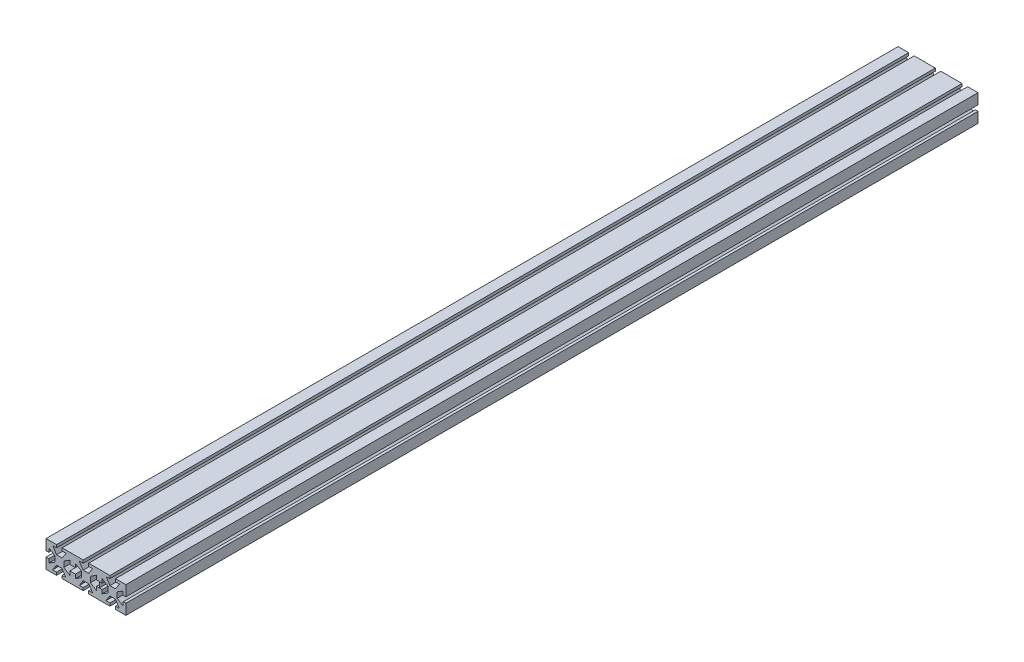
from build123d import *

# Parameters (mm, degrees)
SKETCH1_W            = 114.3
SKETCH1_H            = 1219.2
BASE_EXTRUDE_DEPTH   = 38.1
CUT_EXTRUDE1_DEPTH   = 1220.2
MIRROR2_COPY_1_DEPTH = 1220.2
MIRROR2_COPY_2_DEPTH = 1220.2


with BuildPart() as part:
    # Sketch1 → Base Extrude (new body)
    with BuildSketch(Plane(origin=(0, 0, 0), x_dir=(1, 0, 0), z_dir=(0, 1, 0))):
        Rectangle(SKETCH1_W, SKETCH1_H)
    extrude(amount=BASE_EXTRUDE_DEPTH)

    # Sketch3 → Cut-Extrude1 (cut, through all)
    with BuildSketch(Plane.XY.offset(609.6)):
        Polygon((-42.06875, 38.1), (-34.13125, 38.1), (-34.13125, 34.13125), (-28.347265172, 34.13125), (-34.13125, 25.49525), (-42.06875, 25.49525), (-47.397265172, 34.13125), (-42.06875, 34.13125), align=None)
        Polygon((-23.01875, 28.347265172), (-23.01875, 23.01875), (-19.05, 23.01875), (-19.05, 15.08125), (-23.01875, 15.08125), (-23.01875, 9.297265172), (-31.65475, 15.08125), (-31.65475, 23.01875), align=None)
        Polygon((-28.802734828, 3.96875), (-34.13125, 3.96875), (-34.13125, 0), (-42.06875, 0), (-42.06875, 3.96875), (-47.852734828, 3.96875), (-42.06875, 12.60475), (-34.13125, 12.60475), align=None)
        Polygon((-53.18125, 9.752734828), (-53.18125, 15.08125), (-57.15, 15.08125), (-57.15, 23.01875), (-53.18125, 23.01875), (-53.18125, 28.802734828), (-44.54525, 23.01875), (-44.54525, 15.08125), align=None)
    cut_extrude1 = extrude(amount=-CUT_EXTRUDE1_DEPTH, mode=Mode.SUBTRACT)

    # Mirror1: Cut-Extrude1 across plane
    add(cut_extrude1.mirror(Plane.ZY.offset(19.05)), mode=Mode.SUBTRACT)

    # Mirror2 copy 1 sketch → Mirror2 copy 1 (cut, through all)
    with BuildSketch(Plane(origin=(76.3905, 0, 609.6), x_dir=(1, 0, 0), z_dir=(0, 0, 1))):
        Polygon((-42.06875, 38.1), (-34.13125, 38.1), (-34.13125, 34.13125), (-28.347265172, 34.13125), (-34.13125, 25.49525), (-42.06875, 25.49525), (-47.397265172, 34.13125), (-42.06875, 34.13125), align=None)
        Polygon((-23.01875, 28.347265172), (-23.01875, 23.01875), (-19.05, 23.01875), (-19.05, 15.08125), (-23.01875, 15.08125), (-23.01875, 9.297265172), (-31.65475, 15.08125), (-31.65475, 23.01875), align=None)
        Polygon((-28.802734828, 3.96875), (-34.13125, 3.96875), (-34.13125, 0), (-42.06875, 0), (-42.06875, 3.96875), (-47.852734828, 3.96875), (-42.06875, 12.60475), (-34.13125, 12.60475), align=None)
        Polygon((-53.18125, 9.752734828), (-53.18125, 15.08125), (-57.15, 15.08125), (-57.15, 23.01875), (-53.18125, 23.01875), (-53.18125, 28.802734828), (-44.54525, 23.01875), (-44.54525, 15.08125), align=None)
    extrude(amount=-MIRROR2_COPY_1_DEPTH, mode=Mode.SUBTRACT)

    # Mirror2 copy 2 sketch → Mirror2 copy 2 (cut, through all)
    with BuildSketch(Plane(origin=(38.2905, 0, 609.6), x_dir=(-1, 0, 0), z_dir=(0, 0, 1))):
        Polygon((-42.06875, -38.1), (-34.13125, -38.1), (-34.13125, -34.13125), (-28.347265172, -34.13125), (-34.13125, -25.49525), (-42.06875, -25.49525), (-47.397265172, -34.13125), (-42.06875, -34.13125), align=None)
        Polygon((-23.01875, -28.347265172), (-23.01875, -23.01875), (-19.05, -23.01875), (-19.05, -15.08125), (-23.01875, -15.08125), (-23.01875, -9.297265172), (-31.65475, -15.08125), (-31.65475, -23.01875), align=None)
        Polygon((-28.802734828, -3.96875), (-34.13125, -3.96875), (-34.13125, 0), (-42.06875, 0), (-42.06875, -3.96875), (-47.852734828, -3.96875), (-42.06875, -12.60475), (-34.13125, -12.60475), align=None)
        Polygon((-53.18125, -9.752734828), (-53.18125, -15.08125), (-57.15, -15.08125), (-57.15, -23.01875), (-53.18125, -23.01875), (-53.18125, -28.802734828), (-44.54525, -23.01875), (-44.54525, -15.08125), align=None)
    extrude(amount=-MIRROR2_COPY_2_DEPTH, mode=Mode.SUBTRACT)


solid = part.part
